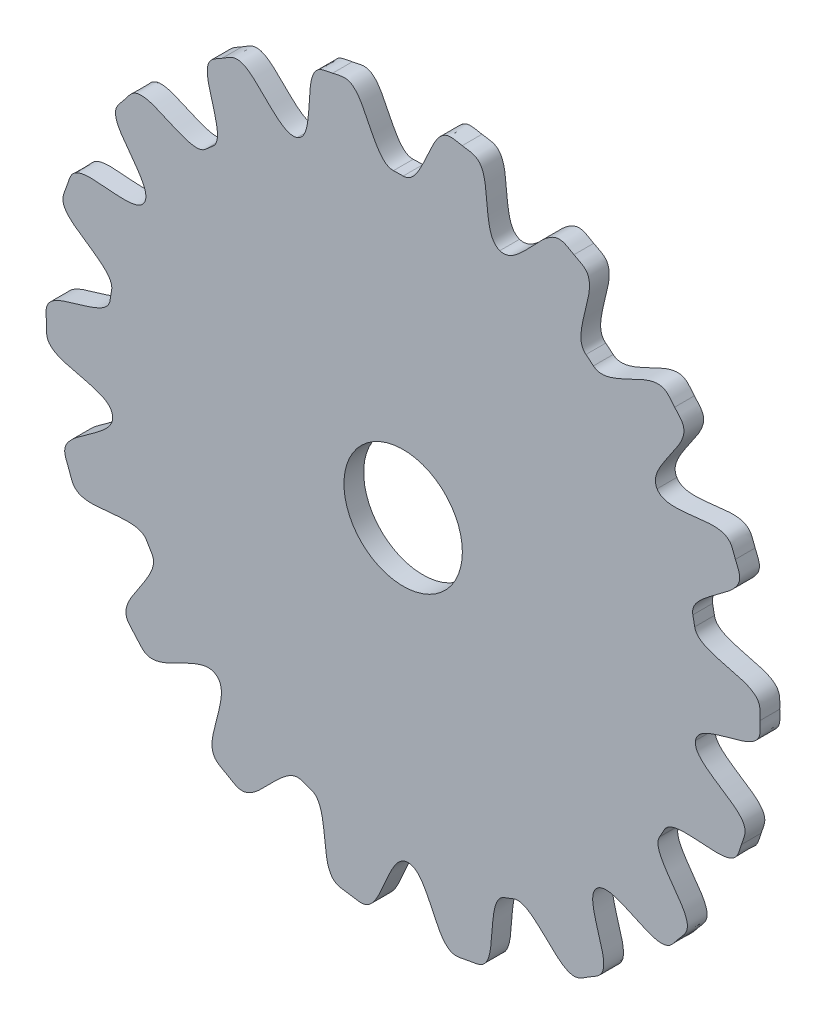
from build123d import *

# Parameters (mm, degrees)
SKETCH2_R           = 15
BOSS_EXTRUDE2_DEPTH = 5


with BuildPart() as part:
    # Sketch2 → Boss-Extrude2 (new body)
    with BuildSketch(Plane.XY):
        with BuildLine():
            ThreePointArc((74.063405158, -11.816083963), (74.765523718, -5.926574639), (75.000052159, 0))
            ThreePointArc((75.000052159, 0), (74.714654317, 6.536685252), (73.860632842, 13.023622382))
            ThreePointArc((73.860632842, 13.023622382), (73.638174028, 14.227689541), (73.396088008, 15.427964512))
            ThreePointArc((73.396088008, 15.427964512), (69.827741951, 27.369586731), (64.331092326, 38.555393708))
            ThreePointArc((64.331092326, 38.555393708), (57.057929937, 48.676487704), (48.209104254, 57.45337319))
            ThreePointArc((48.209104254, 57.45337319), (47.264731464, 58.232748376), (46.307760934, 58.996602454))
            ThreePointArc((46.307760934, 58.996602454), (35.898322464, 65.850727165), (24.497546434, 70.886374167))
            ThreePointArc((24.497546434, 70.886374167), (12.420266985, 73.964483314), (0, 75.000052159))
            ThreePointArc((0, 75.000052159), (-1.224404241, 74.990057062), (-2.448482134, 74.960074434))
            ThreePointArc((-2.448482134, 74.960074434), (-14.828321069, 73.519580508), (-26.798673694, 70.048832339))
            ThreePointArc((-26.798673694, 70.048832339), (-38.028976925, 64.643675158), (-48.209104254, 57.45337319))
            ThreePointArc((-48.209104254, 57.45337319), (-49.140627594, 56.658684626), (-50.0590532, 55.848894497))
            ThreePointArc((-50.0590532, 55.848894497), (-58.616628376, 46.787805053), (-65.555496567, 36.434663354))
            ThreePointArc((-65.555496567, 36.434663354), (-70.684039887, 25.075372961), (-73.860632842, 13.023622382))
            ThreePointArc((-73.860632842, 13.023622382), (-74.063405158, 11.816083963), (-74.246436929, 10.605396134))
            ThreePointArc((-74.246436929, 10.605396134), (-74.977563814, -1.836504375), (-73.638174028, -14.227689541))
            ThreePointArc((-73.638174028, -14.227689541), (-70.26525502, -26.225974926), (-64.951950455, -37.500026079))
            ThreePointArc((-64.951950455, -37.500026079), (-64.331092326, -38.555393708), (-63.693087662, -39.600484946))
            ThreePointArc((-63.693087662, -39.600484946), (-56.255663861, -49.601492996), (-47.264731464, -58.232748376))
            ThreePointArc((-47.264731464, -58.232748376), (-36.968576418, -65.255897676), (-25.651528589, -70.476995572))
            ThreePointArc((-25.651528589, -70.476995572), (-24.497546434, -70.886374167), (-23.337034808, -71.276859009))
            ThreePointArc((-23.337034808, -71.276859009), (-11.211113575, -74.157391784), (1.224404241, -74.990057062))
            ThreePointArc((1.224404241, -74.990057062), (13.62610995, -73.751860665), (25.651528589, -70.476995572))
            ThreePointArc((25.651528589, -70.476995572), (26.798673694, -70.048832339), (27.938675995, -69.601998588))
            ThreePointArc((27.938675995, -69.601998588), (39.07924135, -64.014222789), (49.140627594, -56.658684626))
            ThreePointArc((49.140627594, -56.658684626), (57.844988035, -47.738508388), (64.951950455, -37.500026079))
            ThreePointArc((64.951950455, -37.500026079), (65.555496567, -36.434663354), (66.141569796, -35.359589488))
            ThreePointArc((66.141569796, -35.359589488), (71.08398493, -23.918087513), (74.063405158, -11.816083963))
        make_face()
        Circle(SKETCH2_R, mode=Mode.SUBTRACT)
        with BuildLine():
            ThreePointArc((73.860632842, 13.023622382), (74.714654317, 6.536685252), (75.000052159, 0))
            ThreePointArc((75.000052159, 0), (74.765523718, -5.926574639), (74.063405158, -11.816083963))
            add(Edge.make_bspline(
                [(74.063405158, -11.816083963), (74.361908643, -9.945059297), (80.805828655, -6.624640655), (90.952828083, -5.837483272), (90.418608394, -0.617593234), (90.407542225, 0.738017851)],
                knots=[0, 0, 0, 0, 0.259468979, 0.853076688, 1, 1, 1, 1], degree=3))
            add(Edge.make_bspline(
                [(73.860632842, 13.023622382), (74.189641732, 11.157720246), (80.686910067, 7.942943543), (90.845407869, 7.321544669), (90.396476056, 2.093628936), (90.407542225, 0.738017851)],
                knots=[0, 0, 0, 0, 0.259468979, 0.853076688, 1, 1, 1, 1], degree=3))
        make_face()
        with BuildLine():
            add(Edge.make_bspline(
                [(74.063405158, -11.816083963), (73.764901673, -13.687108629), (78.855746836, -18.847784999), (88.254091344, -22.753208746), (86.122169401, -27.547742249), (85.689840304, -28.832614003)],
                knots=[0, 0, 0, 0, 0.259468979, 0.853076688, 1, 1, 1, 1], degree=3))
            ThreePointArc((74.063405158, -11.816083963), (71.08398493, -23.918087513), (66.141569796, -35.359589488))
            add(Edge.make_bspline(
                [(66.141569796, -35.359589488), (67.03484042, -33.688689962), (74.209878561, -32.655194568), (84.057437349, -35.225564205), (85.257511206, -30.117485758), (85.689840304, -28.832614003)],
                knots=[0, 0, 0, 0, 0.259468979, 0.853076688, 1, 1, 1, 1], degree=3))
        make_face()
        with BuildLine():
            ThreePointArc((64.331092326, 38.555393708), (69.827741951, 27.369586731), (73.396088008, 15.427964512))
            add(Edge.make_bspline(
                [(73.396088008, 15.427964512), (73.006339493, 17.282131098), (77.838419557, 22.685860118), (87.034288999, 27.046731515), (84.670189373, 31.731139231), (84.175473033, 32.993303885)],
                knots=[0, 0, 0, 0, 0.259468979, 0.853076688, 1, 1, 1, 1], degree=3))
            add(Edge.make_bspline(
                [(64.331092326, 38.555393708), (65.305096863, 36.930231318), (72.522129339, 36.249256055), (82.232036919, 39.298667297), (83.680756692, 34.25546854), (84.175473033, 32.993303885)],
                knots=[0, 0, 0, 0, 0.259468979, 0.853076688, 1, 1, 1, 1], degree=3))
        make_face()
        with BuildLine():
            ThreePointArc((48.209104254, 57.45337319), (57.057929937, 48.676487704), (64.331092326, 38.555393708))
            add(Edge.make_bspline(
                [(64.331092326, 38.555393708), (63.357087789, 40.180556098), (66.159092944, 46.866216288), (73.426170457, 53.991579335), (69.661653794, 57.646857296), (68.781806607, 58.678202438)],
                knots=[0, 0, 0, 0, 0.259468979, 0.853076688, 1, 1, 1, 1], degree=3))
            add(Edge.make_bspline(
                [(48.209104254, 57.45337319), (49.66051846, 56.235492065), (56.704133395, 57.949193819), (64.885421684, 64.002931184), (67.901959421, 59.70954758), (68.781806607, 58.678202438)],
                knots=[0, 0, 0, 0, 0.259468979, 0.853076688, 1, 1, 1, 1], degree=3))
        make_face()
        with BuildLine():
            add(Edge.make_bspline(
                [(64.951950455, -37.500026079), (64.004607113, -39.14087288), (66.915384784, -45.779898292), (74.297818078, -52.785673966), (70.593476899, -56.501921955), (69.730584068, -57.547493491)],
                knots=[0, 0, 0, 0, 0.259468979, 0.853076688, 1, 1, 1, 1], degree=3))
            ThreePointArc((64.951950455, -37.500026079), (57.844988035, -47.738508388), (49.140627594, -56.658684626))
            add(Edge.make_bspline(
                [(49.140627594, -56.658684626), (50.571966002, -55.417270919), (57.64261908, -57.015754611), (65.92164662, -62.935122579), (68.867691237, -58.593065026), (69.730584068, -57.547493491)],
                knots=[0, 0, 0, 0, 0.259468979, 0.853076688, 1, 1, 1, 1], degree=3))
        make_face()
        with BuildLine():
            add(Edge.make_bspline(
                [(49.140627594, -56.658684626), (47.709289185, -57.900098333), (48.291884004, -65.125737982), (52.981075594, -74.158605543), (48.266061907, -76.461058281), (47.10897896, -77.167431361)],
                knots=[0, 0, 0, 0, 0.259468979, 0.853076688, 1, 1, 1, 1], degree=3))
            ThreePointArc((49.140627594, -56.658684626), (39.07924135, -64.014222789), (27.938675995, -69.601998588))
            add(Edge.make_bspline(
                [(27.938675995, -69.601998588), (29.696994505, -68.896198581), (35.857710636, -72.716520793), (41.749176569, -81.015426944), (45.951896014, -77.873804441), (47.10897896, -77.167431361)],
                knots=[0, 0, 0, 0, 0.259468979, 0.853076688, 1, 1, 1, 1], degree=3))
        make_face()
        with BuildLine():
            ThreePointArc((24.497546434, 70.886374167), (35.898322464, 65.850727165), (46.307760934, 58.996602454))
            add(Edge.make_bspline(
                [(46.307760934, 58.996602454), (44.817360943, 60.166450947), (45.045498964, 67.411948729), (49.286829548, 76.663560968), (44.464744929, 78.73241152), (43.274466423, 79.381288206)],
                knots=[0, 0, 0, 0, 0.259468979, 0.853076688, 1, 1, 1, 1], degree=3))
            add(Edge.make_bspline(
                [(24.497546434, 70.886374167), (26.288311445, 70.267505597), (32.254601531, 74.384867335), (37.732698512, 82.962260156), (42.084187918, 80.030164892), (43.274466423, 79.381288206)],
                knots=[0, 0, 0, 0, 0.259468979, 0.853076688, 1, 1, 1, 1], degree=3))
        make_face()
        with BuildLine():
            ThreePointArc((0, 75.000052159), (12.420266985, 73.964483314), (24.497546434, 70.886374167))
            add(Edge.make_bspline(
                [(24.497546434, 70.886374167), (22.706781423, 71.505242737), (20.555782369, 78.42784977), (21.542591634, 88.557381922), (16.30923718, 88.937702624), (14.972299253, 89.162203969)],
                knots=[0, 0, 0, 0, 0.259468979, 0.853076688, 1, 1, 1, 1], degree=3))
            add(Edge.make_bspline(
                [(0, 75.000052159), (1.894686684, 75.000052159), (6.188862512, 80.840372273), (8.564825572, 90.736634884), (13.635361326, 89.386705314), (14.972299253, 89.162203969)],
                knots=[0, 0, 0, 0, 0.259468979, 0.853076688, 1, 1, 1, 1], degree=3))
        make_face()
        with BuildLine():
            add(Edge.make_bspline(
                [(25.651528589, -70.476995572), (23.871105493, -71.125016584), (21.833407278, -78.081816929), (22.98545348, -88.193889105), (17.759005343, -88.659595615), (16.425910656, -88.905893059)],
                knots=[0, 0, 0, 0, 0.259468979, 0.853076688, 1, 1, 1, 1], degree=3))
            ThreePointArc((25.651528589, -70.476995572), (13.62610995, -73.751860665), (1.224404241, -74.990057062))
            add(Edge.make_bspline(
                [(1.224404241, -74.990057062), (3.118838424, -74.959125584), (7.507787412, -80.728563325), (10.044994066, -90.584718586), (15.09281597, -89.152190503), (16.425910656, -88.905893059)],
                knots=[0, 0, 0, 0, 0.259468979, 0.853076688, 1, 1, 1, 1], degree=3))
        make_face()
        with BuildLine():
            add(Edge.make_bspline(
                [(1.224404241, -74.990057062), (-0.670029943, -75.020988539), (-4.868288058, -80.930634371), (-7.082374245, -90.864366625), (-12.174272371, -89.597395373), (-13.514697197, -89.394749964)],
                knots=[0, 0, 0, 0, 0.259468979, 0.853076688, 1, 1, 1, 1], degree=3))
            ThreePointArc((1.224404241, -74.990057062), (-11.211113575, -74.157391784), (-23.337034808, -71.276859009))
            add(Edge.make_bspline(
                [(-23.337034808, -71.276859009), (-21.536405185, -71.866410187), (-19.272678609, -78.752978785), (-20.093987918, -88.897271031), (-14.855122022, -89.192104556), (-13.514697197, -89.394749964)],
                knots=[0, 0, 0, 0, 0.259468979, 0.853076688, 1, 1, 1, 1], degree=3))
        make_face()
        with BuildLine():
            ThreePointArc((-26.798673694, 70.048832339), (-14.828321069, 73.519580508), (-2.448482134, 74.960074434))
            add(Edge.make_bspline(
                [(-2.448482134, 74.960074434), (-4.342158882, 74.898219723), (-8.824711219, 80.59523733), (-11.522485211, 90.408658223), (-16.546247839, 88.893913447), (-17.875143967, 88.625885551)],
                knots=[0, 0, 0, 0, 0.259468979, 0.853076688, 1, 1, 1, 1], degree=3))
            add(Edge.make_bspline(
                [(-26.798673694, 70.048832339), (-25.02906706, 70.725833071), (-23.105212804, 77.714972493), (-24.42218888, 87.806889465), (-19.204040096, 88.357857655), (-17.875143967, 88.625885551)],
                knots=[0, 0, 0, 0, 0.259468979, 0.853076688, 1, 1, 1, 1], degree=3))
        make_face()
        with BuildLine():
            ThreePointArc((-48.209104254, 57.45337319), (-38.028976925, 64.643675158), (-26.798673694, 70.048832339))
            add(Edge.make_bspline(
                [(-26.798673694, 70.048832339), (-28.568280329, 69.371831607), (-34.665807229, 73.292220716), (-40.421005234, 81.686201301), (-44.674452768, 78.613608461), (-45.84291332, 77.926219335)],
                knots=[0, 0, 0, 0, 0.259468979, 0.853076688, 1, 1, 1, 1], degree=3))
            add(Edge.make_bspline(
                [(-48.209104254, 57.45337319), (-46.757690048, 58.671254315), (-47.222245923, 65.9054421), (-51.763347613, 75.013658697), (-47.011373873, 77.238830209), (-45.84291332, 77.926219335)],
                knots=[0, 0, 0, 0, 0.259468979, 0.853076688, 1, 1, 1, 1], degree=3))
        make_face()
        with BuildLine():
            add(Edge.make_bspline(
                [(-25.651528589, -70.476995572), (-27.431951685, -69.828974561), (-33.464664144, -73.848385643), (-39.082060256, -82.335203366), (-43.385102183, -79.332459145), (-44.564628905, -78.664237186)],
                knots=[0, 0, 0, 0, 0.259468979, 0.853076688, 1, 1, 1, 1], degree=3))
            ThreePointArc((-25.651528589, -70.476995572), (-36.968576418, -65.255897676), (-47.264731464, -58.232748376))
            add(Edge.make_bspline(
                [(-47.264731464, -58.232748376), (-45.793628315, -59.426772311), (-46.140021426, -66.667580061), (-50.531822849, -75.84871803), (-45.744155627, -77.996015228), (-44.564628905, -78.664237186)],
                knots=[0, 0, 0, 0, 0.259468979, 0.853076688, 1, 1, 1, 1], degree=3))
        make_face()
        with BuildLine():
            add(Edge.make_bspline(
                [(-47.264731464, -58.232748376), (-48.735834614, -57.038724442), (-55.750534032, -58.867187494), (-63.831902463, -65.053680719), (-66.918129305, -60.810115406), (-67.814696336, -59.793271548)],
                knots=[0, 0, 0, 0, 0.259468979, 0.853076688, 1, 1, 1, 1], degree=3))
            ThreePointArc((-47.264731464, -58.232748376), (-56.255663861, -49.601492996), (-63.693087662, -39.600484946))
            add(Edge.make_bspline(
                [(-63.693087662, -39.600484946), (-62.692681537, -41.209529761), (-65.385167342, -47.940042762), (-72.534952138, -55.183094019), (-68.711263367, -58.776427689), (-67.814696336, -59.793271548)],
                knots=[0, 0, 0, 0, 0.259468979, 0.853076688, 1, 1, 1, 1], degree=3))
        make_face()
        with BuildLine():
            ThreePointArc((-65.555496567, 36.434663354), (-58.616628376, 46.787805053), (-50.0590532, 55.848894497))
            add(Edge.make_bspline(
                [(-50.0590532, 55.848894497), (-51.469934309, 54.58427909), (-58.565740947, 56.067118667), (-66.940301081, 61.850539516), (-69.815067351, 57.460965325), (-70.660775836, 56.401446079)],
                knots=[0, 0, 0, 0, 0.259468979, 0.853076688, 1, 1, 1, 1], degree=3))
            add(Edge.make_bspline(
                [(-65.555496567, 36.434663354), (-64.63506692, 38.090757221), (-67.653841281, 44.681378316), (-75.149662674, 51.565699328), (-71.50648432, 55.341926833), (-70.660775836, 56.401446079)],
                knots=[0, 0, 0, 0, 0.259468979, 0.853076688, 1, 1, 1, 1], degree=3))
        make_face()
        with BuildLine():
            ThreePointArc((-73.860632842, 13.023622382), (-70.684039887, 25.075372961), (-65.555496567, 36.434663354))
            add(Edge.make_bspline(
                [(-65.555496567, 36.434663354), (-66.475926214, 34.778569486), (-73.666880357, 33.862347037), (-83.471164524, 36.593139251), (-84.754469764, 31.505333207), (-85.207717263, 30.227690621)],
                knots=[0, 0, 0, 0, 0.259468979, 0.853076688, 1, 1, 1, 1], degree=3))
            add(Edge.make_bspline(
                [(-73.860632842, 13.023622382), (-73.531623953, 14.889524519), (-78.537540674, 20.132623111), (-87.870875163, 24.190957922), (-85.660964763, 28.950048035), (-85.207717263, 30.227690621)],
                knots=[0, 0, 0, 0, 0.259468979, 0.853076688, 1, 1, 1, 1], degree=3))
        make_face()
        with BuildLine():
            add(Edge.make_bspline(
                [(-64.951950455, -37.500026079), (-65.899293797, -35.859179279), (-73.104247295, -35.060473981), (-82.862643649, -37.950960918), (-84.228838226, -32.884783359), (-84.702883321, -31.614710478)],
                knots=[0, 0, 0, 0, 0.259468979, 0.853076688, 1, 1, 1, 1], degree=3))
            ThreePointArc((-64.951950455, -37.500026079), (-70.26525502, -26.225974926), (-73.638174028, -14.227689541))
            add(Edge.make_bspline(
                [(-73.638174028, -14.227689541), (-73.278747426, -16.087971818), (-78.19840145, -21.412095159), (-87.464238254, -25.622259342), (-85.176928416, -30.344637598), (-84.702883321, -31.614710478)],
                knots=[0, 0, 0, 0, 0.259468979, 0.853076688, 1, 1, 1, 1], degree=3))
        make_face()
        with BuildLine():
            add(Edge.make_bspline(
                [(-73.638174028, -14.227689541), (-73.99760063, -12.367407264), (-80.546485535, -9.259129353), (-90.713774106, -8.803654613), (-90.350249825, -3.569106611), (-90.383445383, -2.213856845)],
                knots=[0, 0, 0, 0, 0.259468979, 0.853076688, 1, 1, 1, 1], degree=3))
            ThreePointArc((-73.638174028, -14.227689541), (-74.977563814, -1.836504375), (-74.246436929, 10.605396134))
            add(Edge.make_bspline(
                [(-74.246436929, 10.605396134), (-74.514355447, 8.729747633), (-80.9032096, 5.304572064), (-91.036006117, 4.351865976), (-90.416640942, -0.858607079), (-90.383445383, -2.213856845)],
                knots=[0, 0, 0, 0, 0.259468979, 0.853076688, 1, 1, 1, 1], degree=3))
        make_face()
    extrude(amount=BOSS_EXTRUDE2_DEPTH)


solid = part.part
